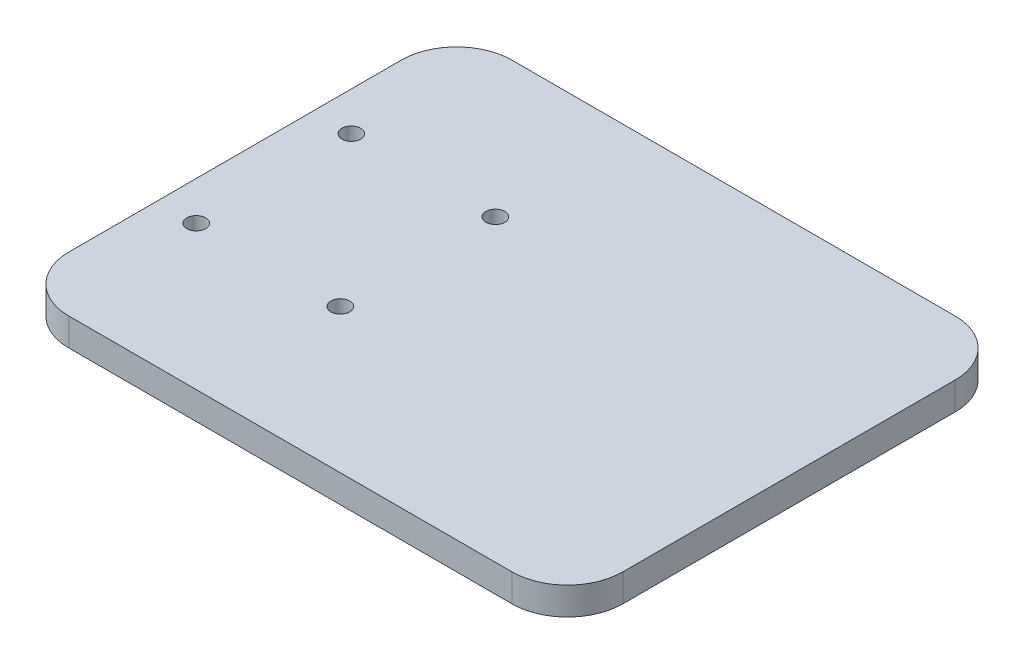
from build123d import *

# Parameters (mm, degrees)
SKETCH1_W            = 100
SKETCH1_H            = 80
BOSS_EXTRUDE1_DEPTH  = 5
M3_CLEARANCE_HOLE1_D = 3.4
FILLET1_R            = 10


with BuildPart() as part:
    # Sketch1 → Boss-Extrude1 (new body)
    with BuildSketch(Plane(origin=(0, 0, 0), x_dir=(1, 0, 0), z_dir=(0, 1, 0))):
        with Locations((30, 0)):
            Rectangle(SKETCH1_W, SKETCH1_H)
    extrude(amount=-BOSS_EXTRUDE1_DEPTH)

    # M3 Clearance Hole1 (through all)
    with Locations(Plane(origin=(-13, 0, -14), x_dir=(0, 0, 1), z_dir=(0, 1, 0))):
        with Locations((0, 0), (0, 26), (28, 26), (28, 0)):
            Hole(M3_CLEARANCE_HOLE1_D / 2)

    # Fillet1
    fillet1_edges = [part.edges().sort_by_distance(p)[0] for p in [
        (-20, -2.5, -40),
        (80, -2.5, -40),
        (80, -2.5, 40),
        (-20, -2.5, 40),
    ]]
    fillet(fillet1_edges, radius=FILLET1_R)


solid = part.part
